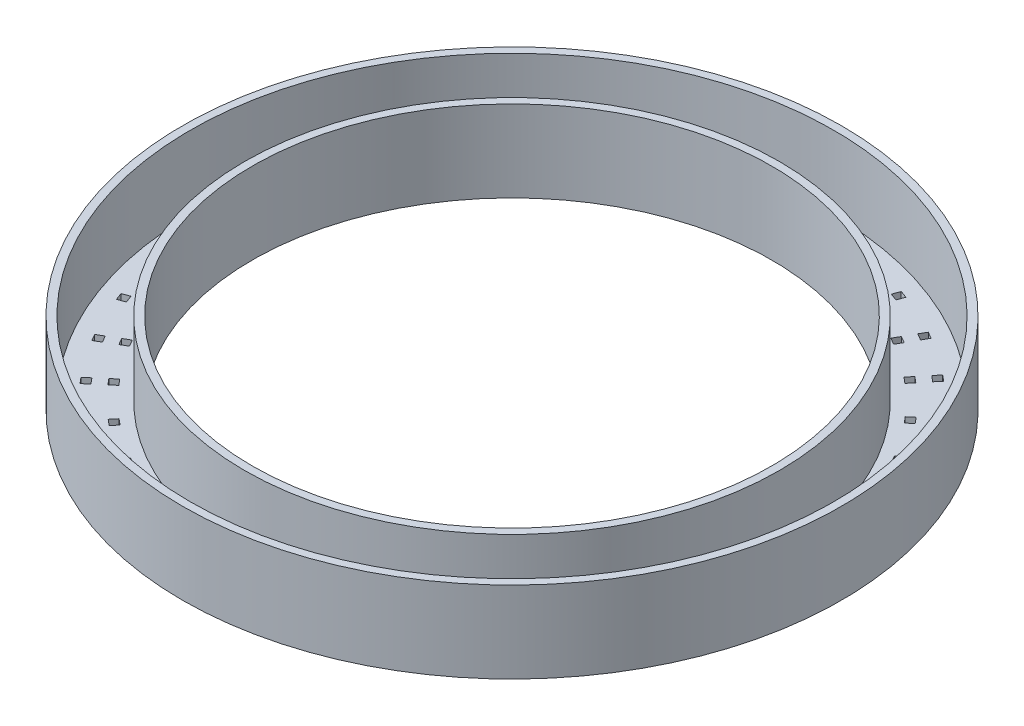
from build123d import *

# Parameters (mm, degrees)
SKETCH1_R           = 42.5
BOSS_EXTRUDE1_DEPTH = 10.5
SKETCH2_R           = 33.5
CUT_EXTRUDE1_DEPTH  = 11.5
SHELL1_T            = -1
SKETCH4_W           = 1
SKETCH4_H           = 1
CUT_EXTRUDE3_DEPTH  = 2
CIRPATTERN1_COUNT   = 36


with BuildPart() as part:
    # Sketch1 → Boss-Extrude1 (new body)
    with BuildSketch(Plane(origin=(0, 0, 0), x_dir=(1, 0, 0), z_dir=(0, 1, 0))):
        Circle(SKETCH1_R)
    extrude(amount=BOSS_EXTRUDE1_DEPTH)

    # Sketch2 → Cut-Extrude1 (cut, through all)
    with BuildSketch(Plane(origin=(0, 10.5, 0), x_dir=(1, 0, 0), z_dir=(0, 1, 0))):
        Circle(SKETCH2_R)
    extrude(amount=-CUT_EXTRUDE1_DEPTH, mode=Mode.SUBTRACT)

    # Shell1
    shell1_openings = [part.faces().sort_by_distance(p)[0] for p in [
        (0, 10.5, 33.5),
    ]]
    offset(amount=SHELL1_T, openings=shell1_openings, kind=Kind.INTERSECTION)

    # Sketch4 → Cut-Extrude3 (cut, through all)
    with BuildSketch(Plane(origin=(0, 1, 0), x_dir=(1, 0, 0), z_dir=(0, 1, 0))):
        with Locations((-0.158801875, 36.435935054)):
            Rectangle(SKETCH4_W, SKETCH4_H)
        with Locations((-0.181953819, 38.982717485)):
            Rectangle(SKETCH4_W, SKETCH4_H)
    cut_extrude3 = extrude(amount=-CUT_EXTRUDE3_DEPTH, mode=Mode.SUBTRACT)

    # CirPattern1: Cut-Extrude3 ×36 about axis
    cirpattern1_axis = Axis((0, 0, 0), (0, 1, 0))
    for i in range(1, CIRPATTERN1_COUNT):
        add(cut_extrude3.rotate(cirpattern1_axis, i * 360 / CIRPATTERN1_COUNT), mode=Mode.SUBTRACT)


solid = part.part
